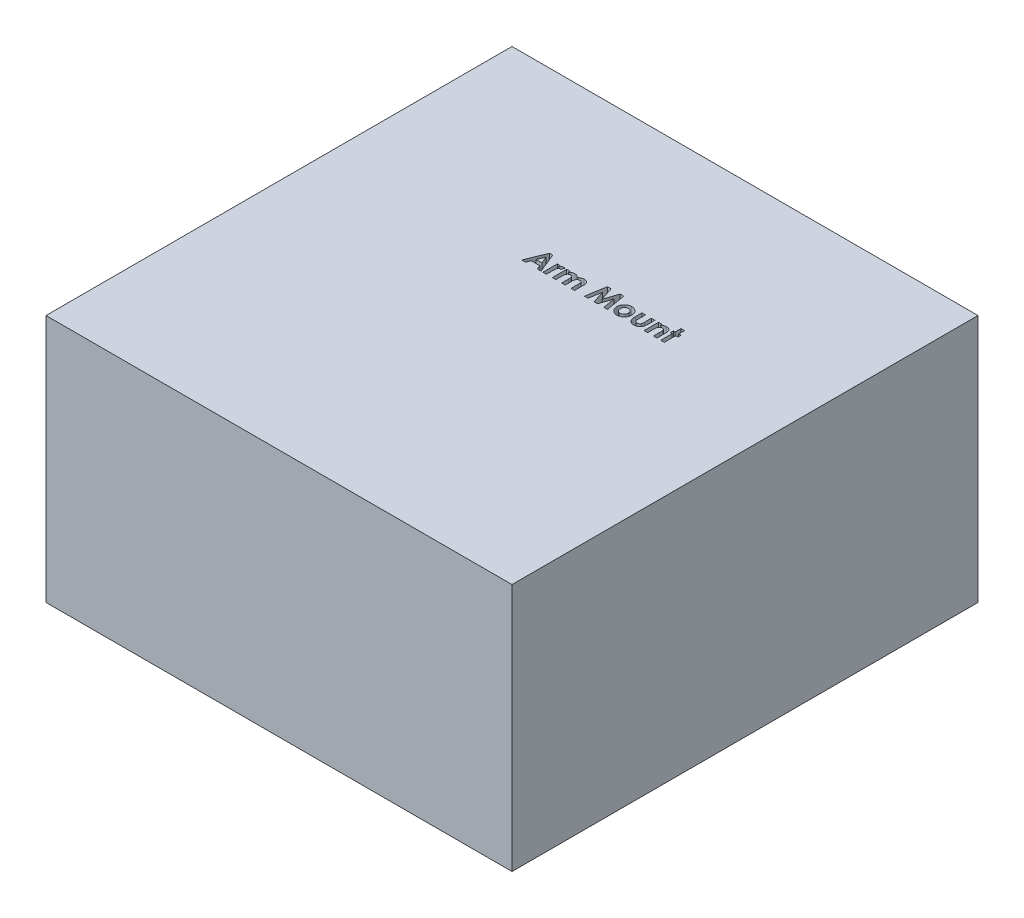
from build123d import *

# Parameters (mm, degrees)
SKETCH1_W           = 300
SKETCH1_H           = 300
BOSS_EXTRUDE1_DEPTH = 160
CUT_EXTRUDE1_DEPTH  = 160


with BuildPart() as part:
    # Sketch1 → Boss-Extrude1 (new body)
    with BuildSketch(Plane(origin=(0, 0, 0), x_dir=(1, 0, 0), z_dir=(0, 1, 0))):
        with Locations((150, 150)):
            Rectangle(SKETCH1_W, SKETCH1_H)
    extrude(amount=BOSS_EXTRUDE1_DEPTH)

    # Sketch2 → Cut-Extrude1 (cut)
    with BuildSketch(Plane(origin=(0, 160, 0), x_dir=(1, 0, 0), z_dir=(0, 1, 0))):
        Polygon((127.3448054, 196.797186132), (129.458927996, 196.797186132), (134.58777415, 184.097186132), (132.153098669, 184.097186132), (131.16599931, 186.702314337), (125.632645945, 186.702314337), (124.645546586, 184.097186132), (122.213415176, 184.097186132), align=None)
        Polygon((128.400594663, 193.390675716), (126.497629919, 188.981801517), (130.303559407, 188.981801517), align=None, mode=Mode.SUBTRACT)
        with BuildLine():
            Line((135.808927996, 193.377955363), (137.76277415, 193.377955363))
            Line((137.76277415, 193.377955363), (137.76277415, 192.235667703))
            add(Edge.make_bspline(
                [(137.76277415, 192.235667703), (137.818044707, 192.337183121), (137.926073303, 192.535599219), (138.124530895, 192.801933536), (138.352527014, 193.026232868), (138.601869055, 193.213188638), (138.873312725, 193.358902303), (139.159589247, 193.46274166), (139.458249528, 193.530222852), (139.661985448, 193.537232872), (139.764957644, 193.540775876)],
                knots=[0, 0, 0, 0, 1.09866127, 2.147379032, 3.14564304, 4.131443017, 5.102343063, 6.064490016, 7.021754664, 8, 8, 8, 8], degree=3))
            add(Edge.make_bspline(
                [(139.764957644, 193.540775876), (139.839728307, 193.537274648), (139.991988075, 193.530144898), (140.224053389, 193.48869955), (140.459466997, 193.413758482), (140.614389438, 193.34628401), (140.693543381, 193.31180953)],
                knots=[0, 0, 0, 0, 0.931404136, 1.896671404, 2.925354185, 4, 4, 4, 4], degree=3))
            Line((140.693543381, 193.31180953), (139.986291778, 191.380860011))
            add(Edge.make_bspline(
                [(139.986291778, 191.380860011), (139.923073585, 191.411403985), (139.804247716, 191.468814899), (139.631733188, 191.536565693), (139.475169101, 191.577903916), (139.375910343, 191.584071941), (139.329921586, 191.586929722)],
                knots=[0, 0, 0, 0, 1.214386998, 2.282580073, 3.20428172, 4, 4, 4, 4], degree=3))
            add(Edge.make_bspline(
                [(139.329921586, 191.586929722), (139.286499256, 191.585036005), (139.201080051, 191.581310738), (139.075003695, 191.549386464), (138.956266021, 191.494334041), (138.839145068, 191.423806424), (138.73288038, 191.325767762), (138.626681329, 191.212270603), (138.533093039, 191.072143265), (138.434330252, 190.91617442), (138.35023727, 190.725268695), (138.278130127, 190.4973666), (138.213882084, 190.229831152), (138.169670659, 189.921241868), (138.126938541, 189.574584882), (138.101503335, 189.187315775), (138.082546155, 188.760659129), (138.08138705, 188.462837392), (138.080782964, 188.307622831)],
                knots=[0, 0, 0, 0, 0.544232178, 1.070598461, 1.618251235, 2.182094276, 2.777567932, 3.425210017, 4.127676488, 4.886675562, 5.738955394, 6.734782583, 7.883056018, 9.186093582, 10.642914445, 12.264202625, 14.053029461, 16, 16, 16, 16], degree=3))
            Line((138.080782964, 188.307622831), (138.088415176, 187.85477828))
            Line((138.088415176, 187.85477828), (138.088415176, 184.097186132))
            Line((138.088415176, 184.097186132), (135.808927996, 184.097186132))
            Line((135.808927996, 184.097186132), (135.808927996, 193.377955363))
        make_face()
        with BuildLine():
            Line((141.833286971, 193.377955363), (144.11277415, 193.377955363))
            Line((144.11277415, 193.377955363), (144.11277415, 192.26874062))
            add(Edge.make_bspline(
                [(144.11277415, 192.26874062), (144.214164582, 192.371072702), (144.413794008, 192.572556161), (144.744619019, 192.831581261), (145.089703004, 193.053079723), (145.453227834, 193.232396668), (145.834304342, 193.369318106), (146.231126425, 193.469652117), (146.645732325, 193.528846041), (146.928022906, 193.536755184), (147.071528157, 193.540775876)],
                knots=[0, 0, 0, 0, 1.041528618, 2.050684245, 3.032913108, 4.004406485, 4.976926473, 5.95771665, 6.961784757, 8, 8, 8, 8], degree=3))
            add(Edge.make_bspline(
                [(147.071528157, 193.540775876), (147.215222885, 193.536256037), (147.498081309, 193.52735888), (147.910769782, 193.445941555), (148.301726174, 193.313665913), (148.666649046, 193.125123238), (149.008175847, 192.892282835), (149.311176713, 192.603115435), (149.583913906, 192.269132165), (149.729293329, 192.016637222), (149.803859887, 191.887130043)],
                knots=[0, 0, 0, 0, 1.023965777, 2.015643508, 2.987309376, 3.958410333, 4.93654923, 5.924956801, 6.93568961, 8, 8, 8, 8], degree=3))
            add(Edge.make_bspline(
                [(149.803859887, 191.887130043), (149.89991125, 192.016989531), (150.088433122, 192.271867264), (150.42260531, 192.604639043), (150.783945146, 192.892312988), (151.179443725, 193.126842229), (151.598597974, 193.313022353), (152.039573727, 193.445450078), (152.498372951, 193.527222809), (152.810611, 193.536220656), (152.968683605, 193.540775876)],
                knots=[0, 0, 0, 0, 1.041189987, 2.043563759, 3.033412161, 4.015238574, 5.00275396, 5.986226558, 6.980513695, 8, 8, 8, 8], degree=3))
            add(Edge.make_bspline(
                [(152.968683605, 193.540775876), (153.131953835, 193.536045982), (153.449907431, 193.526834954), (153.910667849, 193.436214558), (154.342225738, 193.29619245), (154.735043787, 193.092426013), (155.090242353, 192.851056598), (155.39291438, 192.565868562), (155.644104507, 192.246813334), (155.807661492, 191.9488936), (155.913396688, 191.68549844), (155.977240539, 191.456295298), (156.036954292, 191.200361001), (156.079852648, 190.914255432), (156.119896371, 190.600667761), (156.143143327, 190.257513153), (156.158944524, 189.885947615), (156.160622811, 189.628863443), (156.161492099, 189.495703761)],
                knots=[0, 0, 0, 0, 1.321991808, 2.574456155, 3.791773975, 4.987670122, 6.148905103, 7.262530793, 8.344737981, 9.427709016, 10.004683293, 10.642050061, 11.354108788, 12.133887687, 12.985666279, 13.916212488, 14.92067847, 16, 16, 16, 16], degree=3))
            Line((156.161492099, 189.495703761), (156.161492099, 184.097186132))
            Line((156.161492099, 184.097186132), (153.882004919, 184.097186132))
            Line((153.882004919, 184.097186132), (153.882004919, 188.757923312))
            add(Edge.make_bspline(
                [(153.882004919, 188.757923312), (153.880107678, 188.882589368), (153.876466095, 189.121874597), (153.860984321, 189.465083575), (153.82632949, 189.7763445), (153.785709586, 190.057381467), (153.72758172, 190.306704386), (153.656705343, 190.524914281), (153.574489176, 190.712325258), (153.475215633, 190.868917783), (153.364029147, 191.000793424), (153.240350222, 191.113836965), (153.105468398, 191.210285475), (152.958160775, 191.292494122), (152.794568269, 191.348093459), (152.620213506, 191.391718682), (152.433732107, 191.421427771), (152.30479891, 191.42319894), (152.238535368, 191.424109209)],
                knots=[0, 0, 0, 0, 1.669139205, 3.203761885, 4.596586177, 5.860166715, 7.002923539, 8.018877315, 8.928339525, 9.734594377, 10.491888885, 11.231098709, 11.971440889, 12.708030942, 13.480072485, 14.275788656, 15.113863979, 16, 16, 16, 16], degree=3))
            add(Edge.make_bspline(
                [(152.238535368, 191.424109209), (152.136424189, 191.420578961), (151.936051319, 191.413651552), (151.644067208, 191.347452397), (151.369308009, 191.239223864), (151.112803081, 191.091988531), (150.880071842, 190.908094383), (150.676490922, 190.689978388), (150.508361473, 190.436383526), (150.39197817, 190.201098362), (150.319253224, 189.988353297), (150.267952385, 189.806154234), (150.22796542, 189.600114043), (150.196667335, 189.372319435), (150.166640476, 189.121482665), (150.151909467, 188.847920923), (150.13683515, 188.552014254), (150.137031386, 188.347504678), (150.137133125, 188.241476998)],
                knots=[0, 0, 0, 0, 1.129913425, 2.217230253, 3.297175357, 4.391411011, 5.481605898, 6.571841268, 7.681894157, 8.841607612, 9.468549532, 10.170608623, 10.93710061, 11.791434153, 12.717934886, 13.734733707, 14.825576123, 16, 16, 16, 16], degree=3))
            Line((150.137133125, 188.241476998), (150.137133125, 184.097186132))
            Line((150.137133125, 184.097186132), (147.857645945, 184.097186132))
            Line((147.857645945, 184.097186132), (147.857645945, 188.546765459))
            add(Edge.make_bspline(
                [(147.857645945, 188.546765459), (147.857454559, 188.645996937), (147.857086393, 188.836886157), (147.846020075, 189.112533843), (147.831366108, 189.367056681), (147.810822953, 189.601164578), (147.787130468, 189.814566362), (147.752936753, 190.006094578), (147.717013101, 190.176804604), (147.655421513, 190.370726099), (147.568631046, 190.585623569), (147.438964819, 190.81351037), (147.282180641, 191.00431186), (147.102241223, 191.159512881), (146.898901959, 191.277763605), (146.677314067, 191.365727447), (146.433246463, 191.413207629), (146.265246642, 191.420398664), (146.178559407, 191.424109209)],
                knots=[0, 0, 0, 0, 1.256487322, 2.417074606, 3.49288742, 4.484586665, 5.393016842, 6.210437544, 6.947749329, 7.599905853, 8.784490193, 9.876739139, 10.906602197, 11.896672079, 12.869113195, 13.872201355, 14.902064413, 16, 16, 16, 16], degree=3))
            add(Edge.make_bspline(
                [(146.178559407, 191.424109209), (146.08061029, 191.420784646), (145.886621245, 191.414200322), (145.604046566, 191.343479295), (145.333878968, 191.237236553), (145.082061861, 191.085894605), (144.852836733, 190.897672865), (144.65129409, 190.673352745), (144.484048226, 190.413200323), (144.367148319, 190.171425152), (144.29548379, 189.953372391), (144.242803546, 189.766442357), (144.20430435, 189.555864698), (144.172182718, 189.324003826), (144.142333629, 189.070586055), (144.127541668, 188.794496954), (144.112482246, 188.496042544), (144.112674504, 188.289838596), (144.11277415, 188.182963376)],
                knots=[0, 0, 0, 0, 1.07893236, 2.136834559, 3.195274846, 4.273923004, 5.364443877, 6.458052972, 7.587287137, 8.767908, 9.410170275, 10.118584836, 10.909717261, 11.770069756, 12.702352573, 13.724628867, 14.820678298, 16, 16, 16, 16], degree=3))
            Line((144.11277415, 188.182963376), (144.11277415, 184.097186132))
            Line((144.11277415, 184.097186132), (141.833286971, 184.097186132))
            Line((141.833286971, 184.097186132), (141.833286971, 193.377955363))
        make_face()
        Polygon((164.656143541, 196.797186132), (167.022129118, 196.797186132), (169.919825432, 187.938732607), (172.83787431, 196.797186132), (175.180963253, 196.797186132), (177.328158766, 184.097186132), (175.02068681, 184.097186132), (173.664697227, 192.118640459), (171.023952035, 184.097186132), (168.800434407, 184.097186132), (166.174953637, 192.118640459), (164.821508125, 184.097186132), (162.511492099, 184.097186132), align=None)
        with BuildLine():
            add(Edge.make_bspline(
                [(183.540778958, 193.540775876), (183.648548711, 193.538858039), (183.861981655, 193.535059854), (184.179863363, 193.50344343), (184.492187765, 193.451859931), (184.800750061, 193.385068303), (185.102684962, 193.291483243), (185.399576079, 193.179242434), (185.694077997, 193.050376859), (185.978881236, 192.896981751), (186.256043287, 192.730610766), (186.518809407, 192.54708992), (186.764997503, 192.347860704), (186.999177665, 192.137542407), (187.21043672, 191.906978456), (187.412275254, 191.667278387), (187.593788423, 191.409854585), (187.761843471, 191.140979873), (187.911461671, 190.862209099), (188.041377562, 190.575481494), (188.154132341, 190.284761268), (188.242417073, 189.986507251), (188.315508693, 189.684652317), (188.361634701, 189.375497461), (188.394427094, 189.06221848), (188.398104161, 188.851293289), (188.399953637, 188.745202959)],
                knots=[0, 0, 0, 0, 1.022364134, 2.024744242, 3.027414945, 4.024939316, 5.017584196, 6.023349371, 7.035562955, 8.064994934, 9.090267829, 10.101425541, 11.102933353, 12.093946398, 13.084502048, 14.067315274, 15.065326281, 16.070028806, 17.074376865, 18.064572984, 19.055292013, 20.030201733, 21.013838017, 21.999348303, 22.993720005, 24, 24, 24, 24], degree=3))
            add(Edge.make_bspline(
                [(188.399953637, 188.745202959), (188.398001821, 188.638283798), (188.394121168, 188.425704268), (188.362821089, 188.109478511), (188.311040145, 187.798869844), (188.243992168, 187.492048418), (188.150757329, 187.192940308), (188.041822372, 186.897136541), (187.908100427, 186.608669034), (187.760260963, 186.324390878), (187.591125392, 186.05266751), (187.409769344, 185.792664943), (187.208776209, 185.551204265), (186.999208341, 185.320797108), (186.771125464, 185.109234811), (186.528168204, 184.913082167), (186.272439898, 184.729941122), (186.002101589, 184.56410851), (185.720615859, 184.418397307), (185.432729913, 184.287026767), (185.136760353, 184.177651412), (184.833319704, 184.088458822), (184.522223941, 184.019399232), (184.204159881, 183.972486231), (183.879812518, 183.93985878), (183.661280036, 183.936208461), (183.55095524, 183.93436562)],
                knots=[0, 0, 0, 0, 1.012026251, 2.012137606, 3.004615893, 3.992048833, 4.982446996, 5.968083444, 6.973977695, 7.990229942, 8.999482246, 10.001782172, 10.988562221, 11.971415814, 12.948383116, 13.930088534, 14.925840678, 15.924049238, 16.929462851, 17.924729459, 18.917889337, 19.913673841, 20.916777188, 21.931792057, 22.95587778, 24, 24, 24, 24], degree=3))
            add(Edge.make_bspline(
                [(183.55095524, 183.93436562), (183.389637891, 183.939100602), (183.07167894, 183.948433324), (182.603400579, 184.012360029), (182.153539656, 184.12239465), (181.721363127, 184.275780484), (181.306309584, 184.472338715), (180.912001283, 184.715609375), (180.534515932, 185.000803161), (180.18039186, 185.32550959), (179.855966238, 185.681741947), (179.572541424, 186.062017817), (179.33189082, 186.460637504), (179.134230941, 186.878055569), (178.98167782, 187.314844406), (178.871508438, 187.769698167), (178.807503575, 188.243895382), (178.798249786, 188.566078648), (178.793543381, 188.729938536)],
                knots=[0, 0, 0, 0, 1.029999031, 2.030143771, 3.011211297, 3.982305373, 4.953580601, 5.938004764, 6.935448627, 7.970290061, 9.001484052, 10.007591832, 10.993831261, 11.969999897, 12.951306496, 13.942897864, 14.953773953, 16, 16, 16, 16], degree=3))
            add(Edge.make_bspline(
                [(178.793543381, 188.729938536), (178.798413912, 188.904904976), (178.807986844, 189.248798011), (178.884000136, 189.752609144), (179.005385162, 190.234984428), (179.179625721, 190.694574504), (179.402202711, 191.132227027), (179.673918772, 191.547018937), (179.996116743, 191.93904419), (180.242855871, 192.176154503), (180.368323028, 192.296725395)],
                knots=[0, 0, 0, 0, 1.043912699, 2.05178951, 3.033892, 4.007821512, 4.978932272, 5.95884105, 6.962068106, 8, 8, 8, 8], degree=3))
            add(Edge.make_bspline(
                [(180.368323028, 192.296725395), (180.483451686, 192.396665103), (180.710576696, 192.593825457), (181.079580083, 192.843891044), (181.457397914, 193.05987142), (181.848558495, 193.23744746), (182.254152284, 193.371336929), (182.672100841, 193.468796483), (183.102317261, 193.528658997), (183.393882322, 193.536716391), (183.540778958, 193.540775876)],
                knots=[0, 0, 0, 0, 1.048115528, 2.067714963, 3.060638214, 4.039924844, 5.017819947, 5.994373833, 6.98952318, 8, 8, 8, 8], degree=3))
        make_face()
        with BuildLine():
            add(Edge.make_bspline(
                [(183.591660368, 191.424109209), (183.50340488, 191.421175889), (183.329673001, 191.415401617), (183.073935112, 191.38441264), (182.832055523, 191.320898071), (182.599230054, 191.240124922), (182.379577413, 191.132102216), (182.167082094, 191.005690756), (181.972793387, 190.847502369), (181.78730904, 190.673981281), (181.618930598, 190.48129077), (181.475456176, 190.271354603), (181.347258602, 190.052204497), (181.250052882, 189.815817093), (181.169605857, 189.568653546), (181.115160275, 189.306720445), (181.077269952, 189.032943724), (181.074457132, 188.845404794), (181.07303056, 188.7502911)],
                knots=[0, 0, 0, 0, 1.030650113, 2.02884584, 2.99876339, 3.944280128, 4.900564847, 5.851248946, 6.823638398, 7.81794922, 8.81432732, 9.802856497, 10.78262424, 11.771747962, 12.779760563, 13.812642396, 14.89064281, 16, 16, 16, 16], degree=3))
            add(Edge.make_bspline(
                [(181.07303056, 188.7502911), (181.074699843, 188.651823219), (181.077962135, 188.459386655), (181.111743852, 188.178403394), (181.167451017, 187.911752142), (181.24659344, 187.659844817), (181.3461284, 187.42087326), (181.468246253, 187.196178262), (181.614235817, 186.987110828), (181.779752549, 186.793928408), (181.960986301, 186.618574589), (182.159568078, 186.468092502), (182.367182023, 186.337343541), (182.588612688, 186.232331945), (182.820715123, 186.151254472), (183.064178344, 186.091559857), (183.32028175, 186.059399292), (183.4949038, 186.053859638), (183.584028157, 186.051032286)],
                knots=[0, 0, 0, 0, 1.141730614, 2.231293227, 3.276944405, 4.297399982, 5.28939179, 6.275415646, 7.257752684, 8.24146775, 9.222424823, 10.176631434, 11.126518621, 12.063689483, 13.012557477, 13.974037417, 14.965980454, 16, 16, 16, 16], degree=3))
            add(Edge.make_bspline(
                [(183.584028157, 186.051032286), (183.673197089, 186.05354002), (183.84801996, 186.058456634), (184.104424112, 186.095274307), (184.349130635, 186.153218067), (184.583215406, 186.234993345), (184.804785829, 186.342252658), (185.014690093, 186.47362714), (185.214774753, 186.626202297), (185.39844068, 186.80486471), (185.568456716, 186.998649596), (185.717550611, 187.208820683), (185.842139092, 187.433515738), (185.944323955, 187.671320979), (186.023621525, 187.921909544), (186.078406446, 188.186212839), (186.116317028, 188.463411768), (186.119066233, 188.653483667), (186.120466458, 188.7502911)],
                knots=[0, 0, 0, 0, 1.031504075, 2.022346795, 2.991027682, 3.937587355, 4.885570121, 5.833146507, 6.798790848, 7.791235734, 8.792807298, 9.778388351, 10.766749885, 11.760164525, 12.768777521, 13.802286646, 14.880660483, 16, 16, 16, 16], degree=3))
            add(Edge.make_bspline(
                [(186.120466458, 188.7502911), (186.11877594, 188.847064698), (186.115458596, 189.036965891), (186.081674471, 189.314539728), (186.026514001, 189.577988721), (185.946350815, 189.826187964), (185.847407477, 190.061969018), (185.725205217, 190.284125007), (185.578495678, 190.491561756), (185.412174323, 190.683250678), (185.228223764, 190.856143885), (185.033089845, 191.010322655), (184.822310454, 191.137840343), (184.59983994, 191.242960438), (184.365086413, 191.323835345), (184.118313424, 191.383868266), (183.858764691, 191.4155712), (183.681625663, 191.421233462), (183.591660368, 191.424109209)],
                knots=[0, 0, 0, 0, 1.123894411, 2.205445421, 3.243160173, 4.246488011, 5.231014757, 6.210004299, 7.185865357, 8.177612767, 9.153374344, 10.115157457, 11.061423229, 12.009021698, 12.96873347, 13.94135618, 14.954456845, 16, 16, 16, 16], degree=3))
        make_face(mode=Mode.SUBTRACT)
        with BuildLine():
            Line((190.353799791, 193.377955363), (192.633286971, 193.377955363))
            Line((192.633286971, 193.377955363), (192.633286971, 188.923287895))
            add(Edge.make_bspline(
                [(192.633286971, 188.923287895), (192.63348939, 188.818970336), (192.633877883, 188.618759464), (192.644688368, 188.331217456), (192.659857615, 188.068273456), (192.67878781, 187.829617406), (192.707042338, 187.615823353), (192.739661, 187.427299435), (192.77664004, 187.262687316), (192.836772628, 187.079205161), (192.930851149, 186.878419233), (193.072926367, 186.66526139), (193.245020897, 186.480942183), (193.444809623, 186.323825874), (193.674332881, 186.200014772), (193.930428441, 186.116109878), (194.209874098, 186.059717065), (194.404507581, 186.054003508), (194.505722868, 186.051032286)],
                knots=[0, 0, 0, 0, 1.267339619, 2.432334223, 3.495366327, 4.467371443, 5.340232306, 6.114347373, 6.791623365, 7.387877112, 8.457231658, 9.474542289, 10.487879852, 11.508108106, 12.54995813, 13.638205937, 14.771795776, 16, 16, 16, 16], degree=3))
            add(Edge.make_bspline(
                [(194.505722868, 186.051032286), (194.606848336, 186.054423516), (194.801985173, 186.060967404), (195.08329009, 186.111998387), (195.339988855, 186.199441676), (195.574717927, 186.318048178), (195.780555133, 186.476782779), (195.959769169, 186.665926317), (196.110663182, 186.888529909), (196.183174714, 187.054585811), (196.220426394, 187.139894466)],
                knots=[0, 0, 0, 0, 1.116871431, 2.155171802, 3.144773418, 4.104381479, 5.046960687, 6.001340237, 6.973219418, 8, 8, 8, 8], degree=3))
            add(Edge.make_bspline(
                [(196.220426394, 187.139894466), (196.234096509, 187.177789335), (196.264271711, 187.261437889), (196.291128237, 187.405743155), (196.320033858, 187.575927852), (196.34289923, 187.775460201), (196.355837264, 188.003104477), (196.369699043, 188.259147592), (196.376763255, 188.543334543), (196.377679351, 188.742656176), (196.378158766, 188.84696578)],
                knots=[0, 0, 0, 0, 0.56094539, 1.238222264, 2.041156151, 2.969685991, 4.036367568, 5.220421584, 6.545382566, 8, 8, 8, 8], degree=3))
            Line((196.378158766, 188.84696578), (196.378158766, 193.377955363))
            Line((196.378158766, 193.377955363), (198.657645945, 193.377955363))
            Line((198.657645945, 193.377955363), (198.657645945, 189.477895267))
            add(Edge.make_bspline(
                [(198.657645945, 189.477895267), (198.657251254, 189.284522017), (198.656494512, 188.913766968), (198.634806749, 188.381930899), (198.604875178, 187.898385762), (198.566329073, 187.461800203), (198.510788898, 187.071993036), (198.442610374, 186.729878372), (198.367183159, 186.433195469), (198.298013592, 186.257408798), (198.265859086, 186.175691741)],
                knots=[0, 0, 0, 0, 1.388070971, 2.661352173, 3.82033814, 4.865898334, 5.806910977, 6.645039373, 7.370126333, 8, 8, 8, 8], degree=3))
            add(Edge.make_bspline(
                [(198.265859086, 186.175691741), (198.224645292, 186.087738941), (198.143292802, 185.914127669), (198.002131111, 185.667290889), (197.8499509, 185.433432595), (197.679511378, 185.218057582), (197.494291744, 185.01897691), (197.299527574, 184.83166499), (197.086447703, 184.663749446), (196.860578078, 184.510909338), (196.618767002, 184.375234463), (196.362670705, 184.255003543), (196.089521659, 184.15715619), (195.80168839, 184.074216758), (195.497844174, 184.012364558), (195.178601071, 183.965516235), (194.843608948, 183.941304843), (194.615150525, 183.936716594), (194.498090657, 183.93436562)],
                knots=[0, 0, 0, 0, 0.997311338, 1.968606903, 2.91805772, 3.860812155, 4.785445165, 5.709667791, 6.633356648, 7.568312411, 8.508286151, 9.478643871, 10.470653671, 11.485274776, 12.552984541, 13.653035246, 14.797438149, 16, 16, 16, 16], degree=3))
            add(Edge.make_bspline(
                [(194.498090657, 183.93436562), (194.371633105, 183.93587266), (194.124198558, 183.938821427), (193.762700141, 183.974932265), (193.41818729, 184.021654996), (193.094506469, 184.101092202), (192.787137326, 184.193124178), (192.49960863, 184.31058146), (192.230745468, 184.448677943), (191.980018816, 184.606594916), (191.749373217, 184.785779518), (191.533680011, 184.97848632), (191.339902698, 185.192382514), (191.161715241, 185.420862902), (191.001106309, 185.666030301), (190.857996188, 185.927012968), (190.732263656, 186.204997987), (190.665179113, 186.399825791), (190.631103477, 186.498788696)],
                knots=[0, 0, 0, 0, 1.211240017, 2.369985978, 3.478996442, 4.539426614, 5.559871561, 6.551301256, 7.510778031, 8.453136967, 9.386094087, 10.30661716, 11.221130616, 12.147659962, 13.080758632, 14.026335491, 14.997475882, 16, 16, 16, 16], degree=3))
            add(Edge.make_bspline(
                [(190.631103477, 186.498788696), (190.607855968, 186.575647077), (190.557775412, 186.741217945), (190.503703757, 187.016377402), (190.460455281, 187.333514083), (190.41838453, 187.692939937), (190.389035206, 188.09525754), (190.369852139, 188.539827961), (190.356890734, 189.027520554), (190.354860459, 189.366795211), (190.353799791, 189.5440411)],
                knots=[0, 0, 0, 0, 0.627914866, 1.352675004, 2.190563461, 3.132055958, 4.183353232, 5.345633452, 6.613289997, 8, 8, 8, 8], degree=3))
            Line((190.353799791, 189.5440411), (190.353799791, 193.377955363))
        make_face()
        with BuildLine():
            Line((200.937133125, 193.377955363), (203.216620304, 193.377955363))
            Line((203.216620304, 193.377955363), (203.216620304, 192.395944145))
            add(Edge.make_bspline(
                [(203.216620304, 192.395944145), (203.346663918, 192.497094746), (203.595202543, 192.690413208), (203.973024166, 192.936895232), (204.329640999, 193.138630871), (204.673002416, 193.292081321), (205.009568768, 193.402482322), (205.344790991, 193.481798855), (205.683661221, 193.532587411), (205.911464272, 193.538047852), (206.02527415, 193.540775876)],
                knots=[0, 0, 0, 0, 1.276643801, 2.439914479, 3.493451431, 4.44993799, 5.350072675, 6.235028322, 7.118224225, 8, 8, 8, 8], degree=3))
            add(Edge.make_bspline(
                [(206.02527415, 193.540775876), (206.140718956, 193.53765831), (206.367346806, 193.531538265), (206.701043827, 193.488733512), (207.019858923, 193.410772497), (207.327376908, 193.307261355), (207.620467775, 193.170632584), (207.902722065, 193.008408087), (208.168077056, 192.810807673), (208.331494407, 192.660324684), (208.414156362, 192.584205363)],
                knots=[0, 0, 0, 0, 1.048836932, 2.058954983, 3.049370783, 4.026390553, 5.001981509, 5.982488534, 6.97947532, 8, 8, 8, 8], degree=3))
            add(Edge.make_bspline(
                [(208.414156362, 192.584205363), (208.480454292, 192.513665011), (208.613535374, 192.372068036), (208.781001194, 192.129759345), (208.924705706, 191.86559852), (209.042451584, 191.576538381), (209.129461046, 191.260990729), (209.196398611, 190.92276693), (209.233958447, 190.559973178), (209.238595385, 190.310737295), (209.240979278, 190.182602799)],
                knots=[0, 0, 0, 0, 0.889584746, 1.785680191, 2.700364693, 3.65222533, 4.649950538, 5.707241244, 6.821271309, 8, 8, 8, 8], degree=3))
            Line((209.240979278, 190.182602799), (209.240979278, 184.097186132))
            Line((209.240979278, 184.097186132), (206.961492099, 184.097186132))
            Line((206.961492099, 184.097186132), (206.961492099, 188.126993825))
            add(Edge.make_bspline(
                [(206.961492099, 188.126993825), (206.961010038, 188.258439131), (206.960086257, 188.510329664), (206.952993664, 188.870822873), (206.939144791, 189.196395054), (206.926521905, 189.487638982), (206.90173816, 189.743520545), (206.879387779, 189.965659669), (206.845093285, 190.15204109), (206.800470586, 190.352522274), (206.722548362, 190.567174043), (206.601577909, 190.793345143), (206.448109925, 190.985482536), (206.268412657, 191.144933198), (206.062684563, 191.271073297), (205.833411571, 191.359820714), (205.581822856, 191.415130283), (205.406518796, 191.421040084), (205.315478477, 191.424109209)],
                knots=[0, 0, 0, 0, 1.49886392, 2.872294502, 4.110984203, 5.214877267, 6.195405875, 7.042225351, 7.75923308, 8.355011229, 9.382752534, 10.352059385, 11.267231453, 12.171456522, 13.078624015, 14.003401117, 14.963110155, 16, 16, 16, 16], degree=3))
            add(Edge.make_bspline(
                [(205.315478477, 191.424109209), (205.197076713, 191.418105024), (204.965459844, 191.406359671), (204.630472379, 191.317788991), (204.322791974, 191.167156336), (204.04493263, 190.95871103), (203.799540727, 190.701359472), (203.597429444, 190.394438217), (203.431656673, 190.045354791), (203.360371917, 189.790467188), (203.323471266, 189.658524273)],
                knots=[0, 0, 0, 0, 0.984188326, 1.925263693, 2.85911992, 3.81709677, 4.80007086, 5.801799564, 6.862098548, 8, 8, 8, 8], degree=3))
            add(Edge.make_bspline(
                [(203.323471266, 189.658524273), (203.314299988, 189.617086717), (203.293846194, 189.524672634), (203.277025537, 189.368549144), (203.253626781, 189.183323738), (203.244859843, 188.965644358), (203.229615101, 188.716541191), (203.223976867, 188.435684679), (203.218328545, 188.123625533), (203.217208582, 187.905664078), (203.216620304, 187.791176517)],
                knots=[0, 0, 0, 0, 0.543362196, 1.211806945, 2.009705693, 2.934833164, 4.000995085, 5.207458376, 6.533175157, 8, 8, 8, 8], degree=3))
            Line((203.216620304, 187.791176517), (203.216620304, 184.097186132))
            Line((203.216620304, 184.097186132), (200.937133125, 184.097186132))
            Line((200.937133125, 184.097186132), (200.937133125, 193.377955363))
        make_face()
        Polygon((211.683286971, 197.122827158), (213.96277415, 197.122827158), (213.96277415, 193.377955363), (215.428158766, 193.377955363), (215.428158766, 191.424109209), (213.96277415, 191.424109209), (213.96277415, 184.097186132), (211.683286971, 184.097186132), (211.683286971, 191.424109209), (210.543543381, 191.424109209), (210.543543381, 193.377955363), (211.683286971, 193.377955363), align=None)
    extrude(amount=-CUT_EXTRUDE1_DEPTH, mode=Mode.SUBTRACT)


with BuildPart() as cut_extrude1_piece_1:
    # of the separate pieces the step leaves, piece 1, a body of its own (cut_extrude1_pieces)
    add(part.part.solids().sort_by_distance((0, 0, 0))[0])


with BuildPart() as cut_extrude1_piece_2:
    # of the separate pieces the step leaves, piece 2, a body of its own (cut_extrude1_pieces)
    add(part.part.solids().sort_by_distance((186.120466458, 0, -188.7502911))[0])


with BuildPart() as cut_extrude1_piece_3:
    # of the separate pieces the step leaves, piece 3, a body of its own (cut_extrude1_pieces)
    add(part.part.solids().sort_by_distance((130.303559407, 0, -188.981801517))[0])


solid = Compound([cut_extrude1_piece_1.part, cut_extrude1_piece_2.part, cut_extrude1_piece_3.part])
